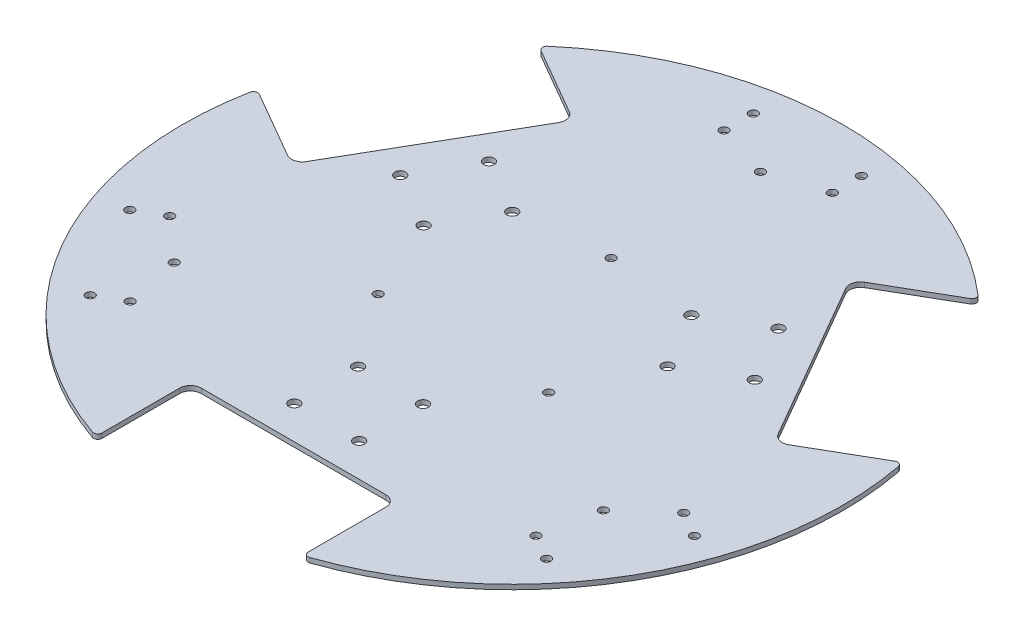
from build123d import *

# Parameters (mm, degrees)
SKETCH1_R           = 2.5
SKETCH1_R_2         = 2
BOSS_EXTRUDE1_DEPTH = 2.2


with BuildPart() as part:
    # Sketch1 → Boss-Extrude1 (new body)
    with BuildSketch(Plane(origin=(0, 0, 0), x_dir=(1, 0, 0), z_dir=(0, 1, 0))):
        with BuildLine():
            Line((-47.65, -142.074373129), (-47.65, -106.264514288))
            ThreePointArc((-47.65, -106.264514288), (-46.185533906, -102.728980382), (-42.65, -101.264514288))
            Line((-42.65, -101.264514288), (42.65, -101.264514288))
            ThreePointArc((42.65, -101.264514288), (46.185533906, -102.728980382), (47.65, -106.264514288))
            Line((47.65, -106.264514288), (47.65, -142.074373129))
            ThreePointArc((47.65, -142.074373129), (48.492330213, -143.705262661), (50.309800664, -143.962404666))
            ThreePointArc((50.309800664, -143.962404666), (132.068874077, -76.25), (149.829999963, 28.411636898))
            ThreePointArc((149.829999963, 28.411636898), (148.698573228, 29.857041477), (146.865016356, 29.771076074))
            Line((146.865016356, 29.771076074), (115.852768895, 11.866146654))
            ThreePointArc((115.852768895, 11.866146654), (112.058673669, 11.366644541), (109.022641876, 13.696273673))
            Line((109.022641876, 13.696273673), (66.372641876, 87.568240616))
            ThreePointArc((66.372641876, 87.568240616), (65.873139763, 91.362335841), (68.202768895, 94.398367635))
            Line((68.202768895, 94.398367635), (99.215016356, 112.303297055))
            ThreePointArc((99.215016356, 112.303297055), (100.206243015, 113.848221184), (99.520199298, 115.550767768))
            ThreePointArc((99.520199298, 115.550767768), (0, 152.5), (-99.520199298, 115.550767768))
            ThreePointArc((-99.520199298, 115.550767768), (-100.206243015, 113.848221184), (-99.215016356, 112.303297055))
            Line((-99.215016356, 112.303297055), (-68.202768895, 94.398367635))
            ThreePointArc((-68.202768895, 94.398367635), (-65.873139763, 91.362335841), (-66.372641876, 87.568240616))
            Line((-66.372641876, 87.568240616), (-109.022641876, 13.696273673))
            ThreePointArc((-109.022641876, 13.696273673), (-112.058673669, 11.366644541), (-115.852768895, 11.866146654))
            Line((-115.852768895, 11.866146654), (-146.865016356, 29.771076074))
            ThreePointArc((-146.865016356, 29.771076074), (-148.698573228, 29.857041477), (-149.829999963, 28.411636898))
            ThreePointArc((-149.829999963, 28.411636898), (-132.068874077, -76.25), (-50.309800664, -143.962404666))
            ThreePointArc((-50.309800664, -143.962404666), (-48.492330213, -143.705262661), (-47.65, -142.074373129))
        make_face()
        with Locations((-15, -85.914514288)):
            Circle(SKETCH1_R, mode=Mode.SUBTRACT)
        with Locations((15, -85.914514288)):
            Circle(SKETCH1_R, mode=Mode.SUBTRACT)
        with Locations((105.474308644, -89.763133948)):
            Circle(SKETCH1_R_2, mode=Mode.SUBTRACT)
        with Locations((130.474308644, -46.461863758)):
            Circle(SKETCH1_R_2, mode=Mode.SUBTRACT)
        with Locations((93.782965693, -83.013133948)):
            Circle(SKETCH1_R_2, mode=Mode.SUBTRACT)
        with Locations((118.782965693, -39.711863758)):
            Circle(SKETCH1_R_2, mode=Mode.SUBTRACT)
        with Locations((99.159908733, -57.25)):
            Circle(SKETCH1_R_2, mode=Mode.SUBTRACT)
        with Locations((39.404155872, -22.75)):
            Circle(SKETCH1_R_2, mode=Mode.SUBTRACT)
        with Locations((-99.159908733, -57.25)):
            Circle(SKETCH1_R_2, mode=Mode.SUBTRACT)
        with Locations((-93.782965693, -83.013133948)):
            Circle(SKETCH1_R_2, mode=Mode.SUBTRACT)
        with Locations((-105.474308644, -89.763133948)):
            Circle(SKETCH1_R_2, mode=Mode.SUBTRACT)
        with Locations((-130.474308644, -46.461863758)):
            Circle(SKETCH1_R_2, mode=Mode.SUBTRACT)
        with Locations((-118.782965693, -39.711863758)):
            Circle(SKETCH1_R_2, mode=Mode.SUBTRACT)
        with Locations((-39.404155872, -22.75)):
            Circle(SKETCH1_R_2, mode=Mode.SUBTRACT)
        with Locations((0, 114.5)):
            Circle(SKETCH1_R_2, mode=Mode.SUBTRACT)
        with Locations((-25, 122.724997706)):
            Circle(SKETCH1_R_2, mode=Mode.SUBTRACT)
        with Locations((-25, 136.224997706)):
            Circle(SKETCH1_R_2, mode=Mode.SUBTRACT)
        with Locations((25, 136.224997706)):
            Circle(SKETCH1_R_2, mode=Mode.SUBTRACT)
        with Locations((25, 122.724997706)):
            Circle(SKETCH1_R_2, mode=Mode.SUBTRACT)
        with Locations((0, 45.5)):
            Circle(SKETCH1_R_2, mode=Mode.SUBTRACT)
        with Locations((15, -56.414514288)):
            Circle(SKETCH1_R, mode=Mode.SUBTRACT)
        with Locations((-15, -56.414514288)):
            Circle(SKETCH1_R, mode=Mode.SUBTRACT)
        with Locations((-56.356402516, 15.216876087)):
            Circle(SKETCH1_R, mode=Mode.SUBTRACT)
        with Locations((-81.904151928, 29.966876087)):
            Circle(SKETCH1_R, mode=Mode.SUBTRACT)
        with Locations((-66.904151928, 55.947638201)):
            Circle(SKETCH1_R, mode=Mode.SUBTRACT)
        with Locations((-41.356402516, 41.197638201)):
            Circle(SKETCH1_R, mode=Mode.SUBTRACT)
        with Locations((41.356402516, 41.197638201)):
            Circle(SKETCH1_R, mode=Mode.SUBTRACT)
        with Locations((66.904151928, 55.947638201)):
            Circle(SKETCH1_R, mode=Mode.SUBTRACT)
        with Locations((81.904151928, 29.966876087)):
            Circle(SKETCH1_R, mode=Mode.SUBTRACT)
        with Locations((56.356402516, 15.216876087)):
            Circle(SKETCH1_R, mode=Mode.SUBTRACT)
    extrude(amount=BOSS_EXTRUDE1_DEPTH)


solid = part.part
